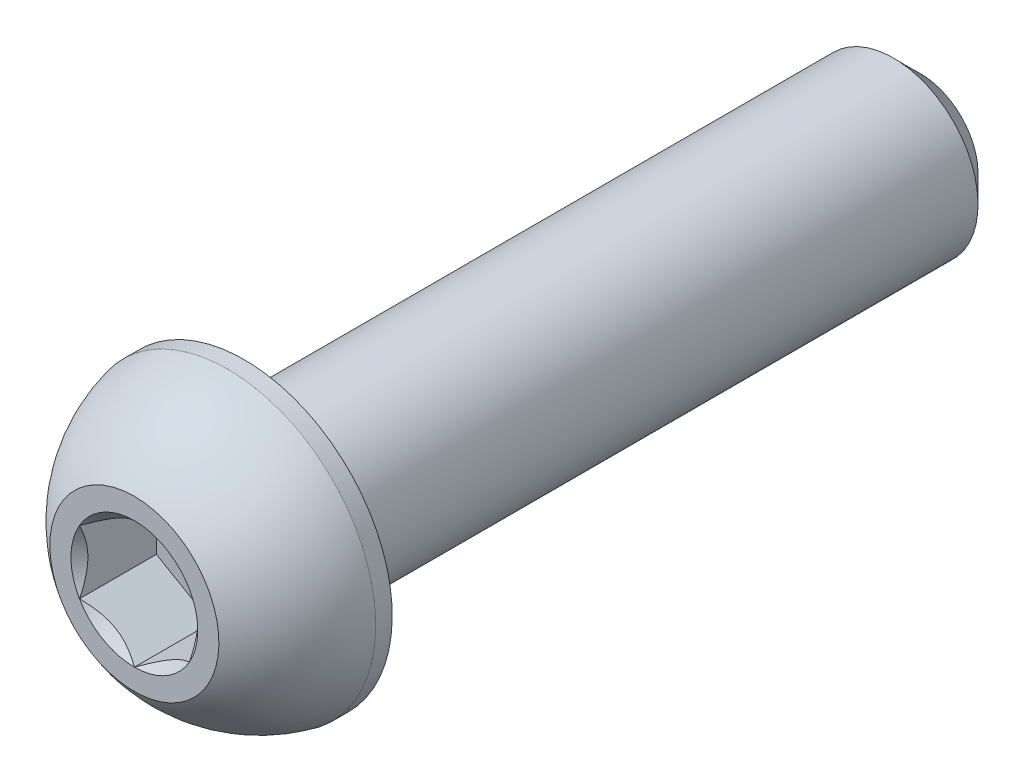
from build123d import *

# Parameters (mm, degrees)
CUT_EXTRUDE1_DEPTH = 0.91


with BuildPart() as part:
    # Sketch2 → Revolve1 (revolve)
    with BuildSketch(Plane(origin=(0, 0, 0), x_dir=(0, 0, -1), z_dir=(1, 0, 0)), mode=Mode.PRIVATE) as revolve1_sk:
        with BuildLine():
            Line((-4.65, 0), (4.65, 0))
            Line((4.65, 0), (4.65, 0.68))
            Line((4.65, 0.68), (4.33, 1))
            Line((4.33, 1), (-3.35, 1))
            Line((-3.35, 1), (-3.35, 1.75))
            Line((-3.35, 1.75), (-3.545, 1.75))
            ThreePointArc((-3.545, 1.75), (-4.170023043, 1.481850617), (-4.65, 1))
            Line((-4.65, 1), (-4.65, 0))
        make_face()
    revolve(revolve1_sk.sketch.rotate(Axis((0, 0, 4.65), (0, 0, -1)), 180), axis=Axis((0, 0, 4.65), (0, 0, -1)))

    # Sketch3 → Cut-Extrude1 (cut)
    with BuildSketch(Plane.XY.offset(4.65)):
        Polygon((0, 0.75055535), (-0.65, 0.375277675), (-0.65, -0.375277675), (0, -0.75055535), (0.65, -0.375277675), (0.65, 0.375277675), align=None)
    extrude(amount=-CUT_EXTRUDE1_DEPTH, mode=Mode.SUBTRACT)

    # Cut-Extrude2 cone 1 section (through the dimple's axis) → Cut-Extrude2 (revolve, cut)
    with BuildSketch(Plane(origin=(0, 0, 4.65), x_dir=(0, -1, 0), z_dir=(1, 0, 0))):
        Polygon((0, 0), (0.75055535, 0), (0, 0.75055535), align=None)
    revolve(axis=Axis((0, 0, 4.65), (0, 0, -1)), mode=Mode.SUBTRACT)


solid = part.part
